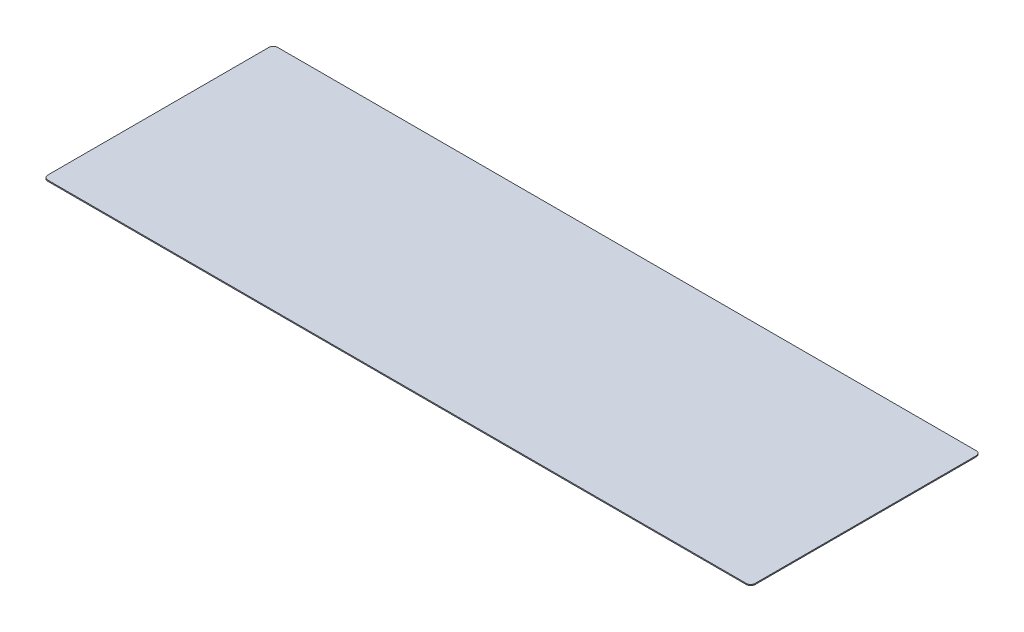
from build123d import *

# Parameters (mm, degrees)
BOSS_EXTRUDE1_DEPTH = 1.524


with BuildPart() as part:
    # Sketch1 → Boss-Extrude1 (new body)
    with BuildSketch(Plane(origin=(0, 0, 0), x_dir=(1, 0, 0), z_dir=(0, 1, 0))):
        with BuildLine():
            Line((6.35, 0), (1009.65, 0))
            ThreePointArc((1009.65, 0), (1014.140128061, 1.859871939), (1016, 6.35))
            Line((1016, 6.35), (1016, 323.85))
            ThreePointArc((1016, 323.85), (1014.140128061, 328.340128061), (1009.65, 330.2))
            Line((1009.65, 330.2), (6.35, 330.2))
            ThreePointArc((6.35, 330.2), (1.859871939, 328.340128061), (0, 323.85))
            Line((0, 323.85), (0, 6.35))
            ThreePointArc((0, 6.35), (1.859871939, 1.859871939), (6.35, 0))
        make_face()
    extrude(amount=BOSS_EXTRUDE1_DEPTH)


solid = part.part
